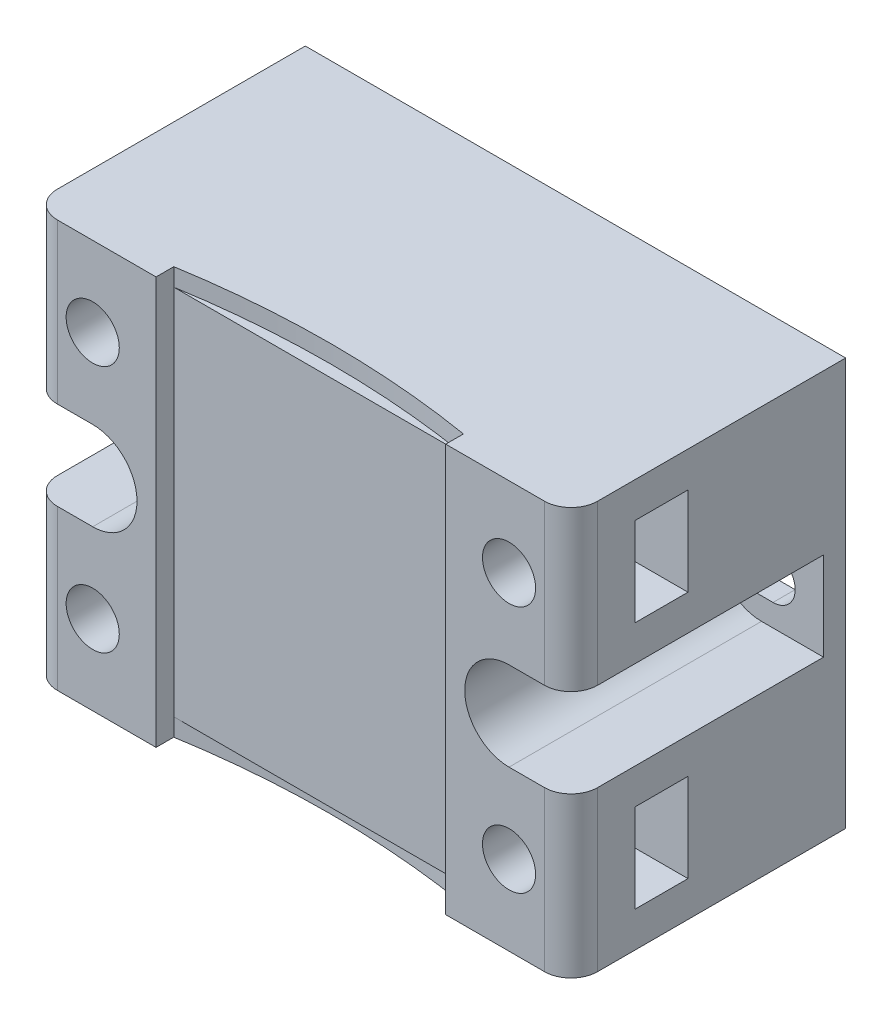
from build123d import *

# Parameters (mm, degrees)
SKETCH_1_W          = 61
SKETCH_1_H          = 46
EXTRUDE_1_DEPTH     = 31
CUT_EXTRUDE_1_DEPTH = 28.5
SKETCH_3_R          = 2.5
CUT_EXTRUDE_2_DEPTH = 28.5
CUT_EXTRUDE_3_DEPTH = 28.5
CUT_EXTRUDE_4_DEPTH = 68.5
CUT_EXTRUDE_5_DEPTH = 2
CUT_EXTRUDE_6_DEPTH = 2
SKETCH_8_R          = 3
CUT_EXTRUDE_7_DEPTH = 7.2
CUT_EXTRUDE_8_DEPTH = 10
CUT_EXTRUDE_9_DEPTH = 10
FILLET_1_R          = 3


with BuildPart() as part:
    # 草图1 → 凸台-拉伸1 (new body)
    with BuildSketch(Plane.XY):
        with Locations((30.5, 23)):
            Rectangle(SKETCH_1_W, SKETCH_1_H)
    extrude(amount=EXTRUDE_1_DEPTH)

    # 草图2 → 切除-拉伸1 (cut)
    with BuildSketch(Plane.XY.offset(31)):
        with BuildLine():
            ThreePointArc((7, 18), (10.535533906, 19.464466094), (12, 23))
            ThreePointArc((12, 23), (10.535533906, 26.535533906), (7, 28))
            Line((7, 28), (0, 28))
            Line((0, 28), (0, 18))
            Line((0, 18), (7, 18))
        make_face()
        with BuildLine():
            Line((61, 18), (61, 28))
            Line((61, 28), (54, 28))
            ThreePointArc((54, 28), (49, 23), (54, 18))
            Line((54, 18), (61, 18))
        make_face()
    extrude(amount=-CUT_EXTRUDE_1_DEPTH, mode=Mode.SUBTRACT)

    # 草图3 → 切除-拉伸2 (cut)
    with BuildSketch(Plane.XY.offset(2.5)):
        with Locations((5.7, 23)):
            Circle(SKETCH_3_R)
    extrude(amount=-CUT_EXTRUDE_2_DEPTH, mode=Mode.SUBTRACT)

    # 草图4 → 切除-拉伸3 (cut)
    with BuildSketch(Plane.XY.offset(2.5)):
        with BuildLine():
            Line((53.3, 25.5), (55.3, 25.5))
            ThreePointArc((55.3, 25.5), (57.8, 23), (55.3, 20.5))
            Line((55.3, 20.5), (53.3, 20.5))
            ThreePointArc((53.3, 20.5), (50.8, 23), (53.3, 25.5))
        make_face()
    extrude(amount=-CUT_EXTRUDE_3_DEPTH, mode=Mode.SUBTRACT)

    # 草图5 → 切除-拉伸4 (cut)
    with BuildSketch(Plane.XZ):
        Polygon((30.5, 31), (46.85, 31), (46.85, 29), (14.15, 29), (14.15, 31), align=None)
    extrude(amount=-CUT_EXTRUDE_4_DEPTH, mode=Mode.SUBTRACT)

    # 草图6 → 切除-拉伸5 (cut)
    with BuildSketch(Plane.XZ):
        with BuildLine():
            Line((14.15, 29), (46.85, 29))
            ThreePointArc((46.85, 29), (30.5, 27.654333407), (14.15, 29))
        make_face()
    extrude(amount=-CUT_EXTRUDE_5_DEPTH, mode=Mode.SUBTRACT)

    # 草图7 → 切除-拉伸6 (cut)
    with BuildSketch(Plane(origin=(0, 46, 0), x_dir=(1, 0, 0), z_dir=(0, 1, 0))):
        with BuildLine():
            Line((14.15, -29), (46.85, -29))
            ThreePointArc((46.85, -29), (30.5, -27.654333407), (14.15, -29))
        make_face()
    extrude(amount=-CUT_EXTRUDE_6_DEPTH, mode=Mode.SUBTRACT)

    # 草图8 → 切除-拉伸7 (cut)
    with BuildSketch(Plane.XY.offset(31)):
        with BuildLine():
            ThreePointArc((10, 37), (9.121320344, 39.121320344), (7, 40))
            Line((7, 40), (7, 37))
            Line((7, 37), (4, 37))
            ThreePointArc((4, 37), (7, 34), (10, 37))
        make_face()
        with BuildLine():
            Line((7, 37), (7, 40))
            ThreePointArc((7, 40), (4.878679656, 39.121320344), (4, 37))
            Line((4, 37), (7, 37))
        make_face()
        with Locations((7, 9)):
            Circle(SKETCH_8_R)
        with Locations((54, 9)):
            Circle(SKETCH_8_R)
        with Locations((54, 37)):
            Circle(SKETCH_8_R)
    extrude(amount=-CUT_EXTRUDE_7_DEPTH, mode=Mode.SUBTRACT)

    # 草图9 → 切除-拉伸8 (cut)
    with BuildSketch(Plane.ZY):
        Polygon((23.8, 32), (23.8, 37), (23.8, 42), (17.8, 42), (17.8, 41.5), (17.8, 32), align=None)
        Polygon((23.8, 4), (23.8, 14), (17.8, 14), (17.8, 4.5), (17.8, 4), align=None)
    extrude(amount=-CUT_EXTRUDE_8_DEPTH, mode=Mode.SUBTRACT)

    # 草图10 → 切除-拉伸9 (cut)
    with BuildSketch(Plane(origin=(61, 0, 0), x_dir=(0, 0, -1), z_dir=(1, 0, 0))):
        Polygon((-23.8, 4), (-23.8, 9), (-23.8, 14), (-17.8, 14), (-17.8, 4), align=None)
        Polygon((-23.8, 42), (-17.8, 42), (-17.8, 32), (-23.8, 32), (-23.8, 37), align=None)
    extrude(amount=-CUT_EXTRUDE_9_DEPTH, mode=Mode.SUBTRACT)

    # 圆角1
    fillet_1_edges = [part.edges().sort_by_distance(p)[0] for p in [
        (61, 9, 31),
        (0, 9, 31),
        (61, 37, 31),
        (0, 37, 31),
    ]]
    fillet(fillet_1_edges, radius=FILLET_1_R)


solid = part.part
